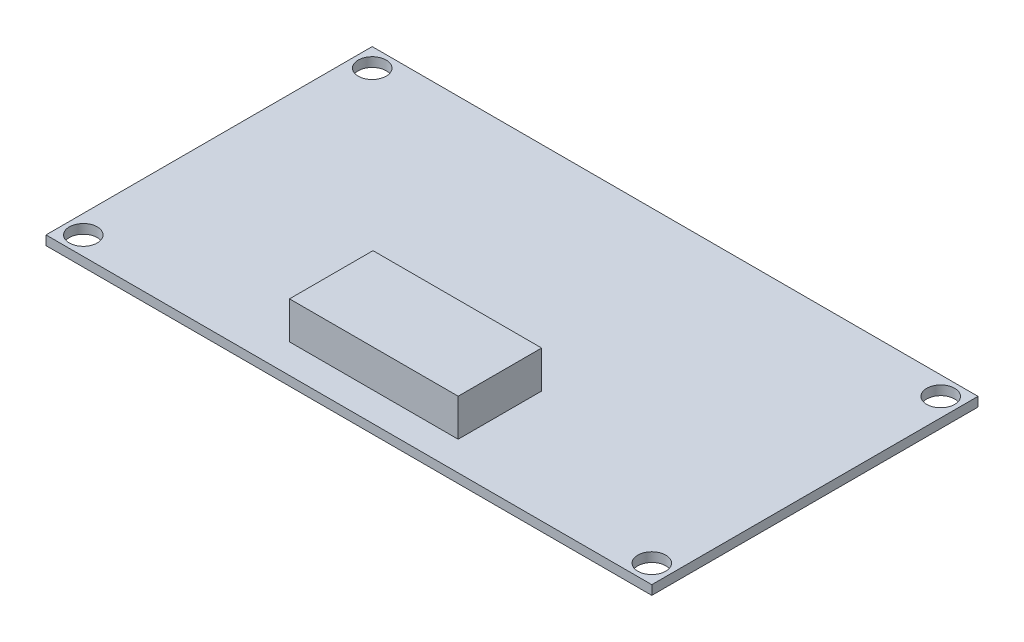
from build123d import *

# Parameters (mm, degrees)
SKETCH_2_W                = 65
SKETCH_2_H                = 35
EXTRUDE_1_DEPTH           = 1
HOLE_WIZARD_3_0_3_1_D     = 3
HOLE_WIZARD_3_0_3_1_DEPTH = 12.4
HOLE_WIZARD_3_0_3_1_TIP   = 0.901290929
SKETCH_5_W                = 18.093294379
SKETCH_5_H                = 8.957076426
EXTRUDE_2_DEPTH           = 4


with BuildPart() as part:
    # 草图2 → 凸台-拉伸1 (new body)
    with BuildSketch(Plane(origin=(0, 0, 0), x_dir=(1, 0, 0), z_dir=(0, 1, 0))):
        Rectangle(SKETCH_2_W, SKETCH_2_H)
    extrude(amount=EXTRUDE_1_DEPTH)

    # Ø3.0 (3) 直径孔1
    with Locations(Plane(origin=(0, 1, 0), x_dir=(1, 0, 0), z_dir=(0, 1, 0))):
        with Locations((-30.5, 15.5), (-30.5, -15.5), (30.5, -15.5), (30.5, 15.5)):
            Hole(HOLE_WIZARD_3_0_3_1_D / 2, depth=HOLE_WIZARD_3_0_3_1_DEPTH)
            with Locations((0, 0, -(HOLE_WIZARD_3_0_3_1_DEPTH + HOLE_WIZARD_3_0_3_1_TIP / 2))):  # 118° drill point
                Cone(0, HOLE_WIZARD_3_0_3_1_D / 2, HOLE_WIZARD_3_0_3_1_TIP, mode=Mode.SUBTRACT)

    # 草图5 → 凸台-拉伸2 (add)
    with BuildSketch(Plane(origin=(0, 1, 0), x_dir=(1, 0, 0), z_dir=(0, 1, 0))):
        with Locations((-0.447853821, -9.89756945)):
            Rectangle(SKETCH_5_W, SKETCH_5_H)
    extrude(amount=EXTRUDE_2_DEPTH)


solid = part.part
